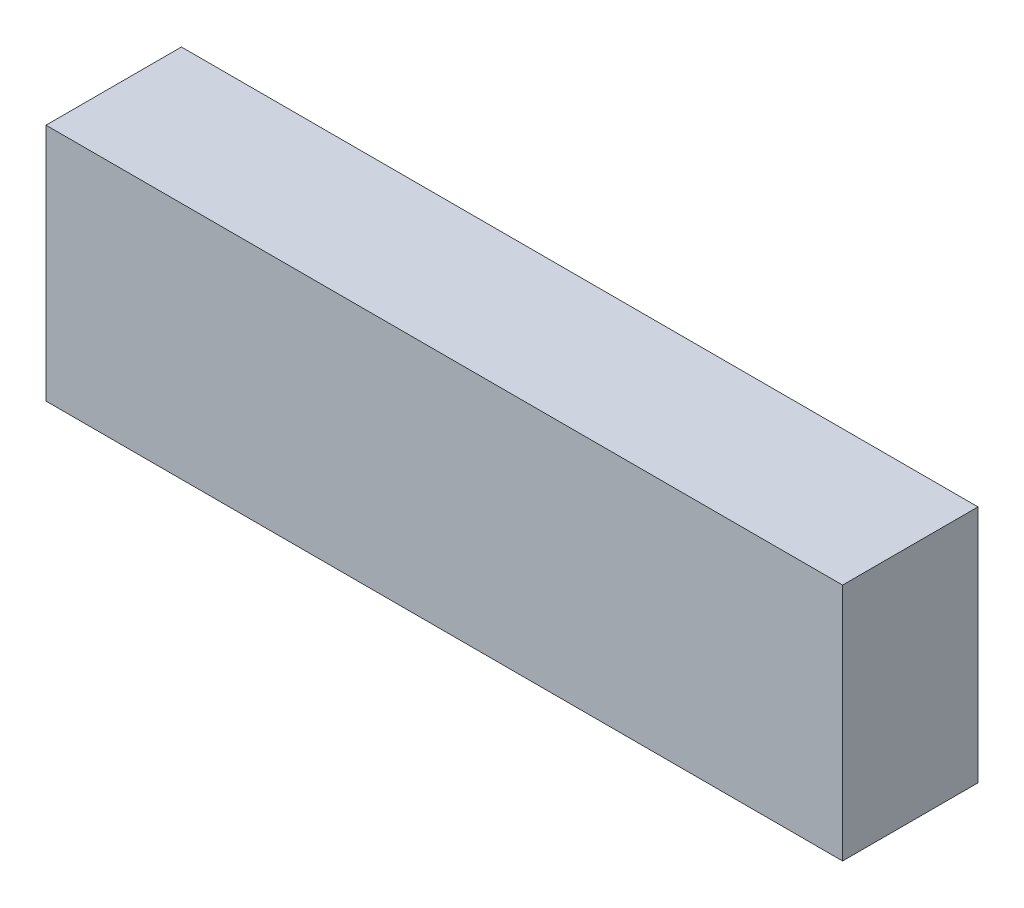
from build123d import *

# Parameters (mm, degrees)
SKETCH_1_W      = 100
SKETCH_1_H      = 30
EXTRUDE_1_DEPTH = 17


with BuildPart() as part:
    # 草圖1 → 填料-伸長1 (new body)
    with BuildSketch(Plane.XY):
        Rectangle(SKETCH_1_W, SKETCH_1_H)
    extrude(amount=EXTRUDE_1_DEPTH)


solid = part.part
